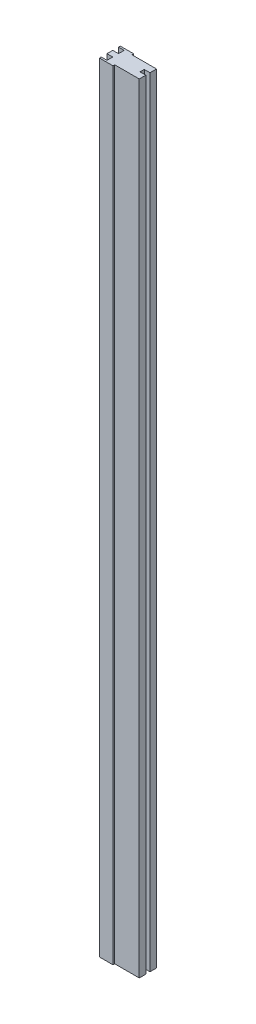
from build123d import *

# Parameters (mm, degrees)
EXTRUDE_1_DEPTH = 1350


with BuildPart() as part:
    # Эскиз1 → Бобышка-Вытянуть1 (new body)
    with BuildSketch(Plane(origin=(0, 0, 0), x_dir=(1, 0, 0), z_dir=(0, 1, 0))):
        Polygon((-10, -14.940308811), (-10, -5), (-20, -5), (-20, 0), (-20, 5), (-10, 5), (-10, 14.940308811), (-20, 14.940308811), (-20, 18), (3.34276046, 18), (3.34276046, 15), (46, 15), (46, 3.685533366), (36, 3.685533366), (36, -3.685533366), (46, -3.685533366), (46, -15), (3.34276046, -15), (3.34276046, -18), (-20, -18), (-20, -14.940308811), align=None)
    extrude(amount=EXTRUDE_1_DEPTH)


solid = part.part
